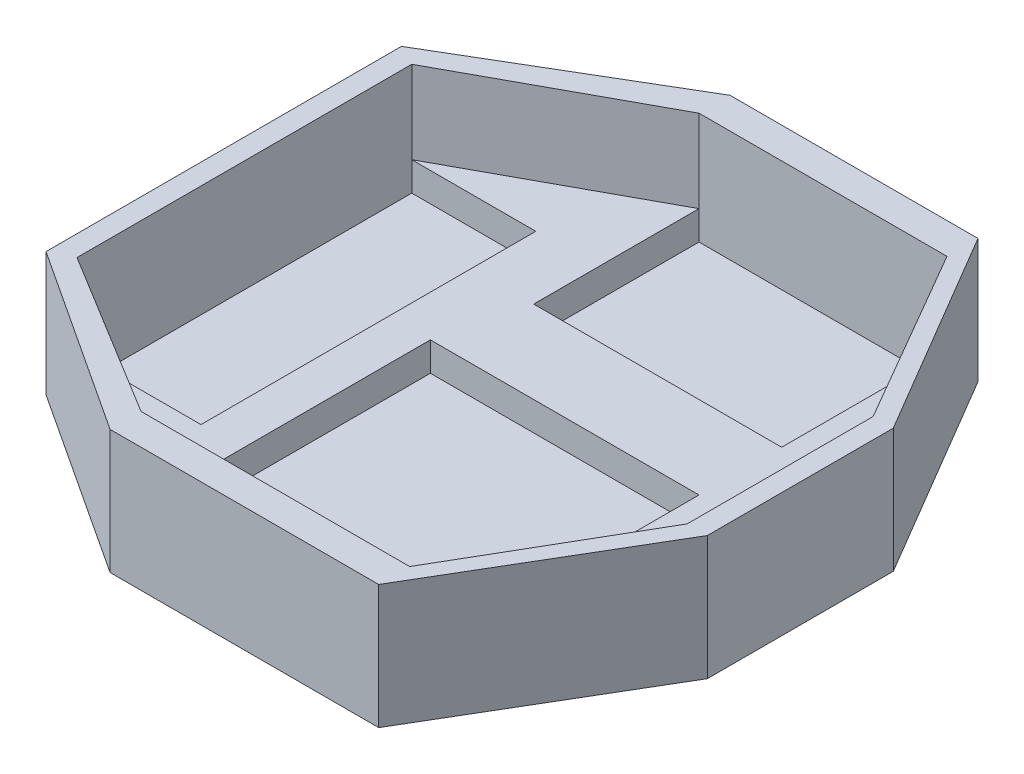
from build123d import *

# Parameters (mm, degrees)
SKETCH1_R           = 85
BOSS_EXTRUDE2_DEPTH = 10
SKETCH3_W           = 30
SKETCH3_H           = 81
SKETCH3_W_2         = 60
SKETCH3_H_2         = 40
SKETCH3_W_3         = 65
SKETCH3_H_3         = 70
CUT_EXTRUDE2_DEPTH  = 7
SKETCH5_W           = 194.063046405
SKETCH5_H           = 184.49419377
CUT_EXTRUDE4_DEPTH  = 10
BOSS_EXTRUDE3_DEPTH = 20


with BuildPart() as part:
    # Sketch1 → Boss-Extrude2 (new body)
    with BuildSketch(Plane(origin=(0, 0, 0), x_dir=(1, 0, 0), z_dir=(0, 1, 0))):
        Circle(SKETCH1_R)
    extrude(amount=BOSS_EXTRUDE2_DEPTH)

    # Sketch3 → Cut-Extrude2 (cut)
    with BuildSketch(Plane(origin=(0, 10, 0), x_dir=(1, 0, 0), z_dir=(0, 1, 0))):
        with Locations((-50, 0)):
            Rectangle(SKETCH3_W, SKETCH3_H)
        with Locations((10, 45)):
            Rectangle(SKETCH3_W_2, SKETCH3_H_2)
        with Locations((7.5, -30)):
            Rectangle(SKETCH3_W_3, SKETCH3_H_3)
    extrude(amount=-CUT_EXTRUDE2_DEPTH, mode=Mode.SUBTRACT)

    # Sketch5 → Cut-Extrude4 (cut)
    with BuildSketch(Plane(origin=(0, 10, 0), x_dir=(1, 0, 0), z_dir=(0, 1, 0))):
        with Locations((-1.510871468, -0.083937304)):
            Rectangle(SKETCH5_W, SKETCH5_H)
        Polygon((-70, 43), (-20, 72.5), (40, 72.5), (69.5, 22.5), (69.5, -22.5), (40, -72.5), (-25, -72.5), (-70, -43), align=None, mode=Mode.SUBTRACT)
    extrude(amount=-CUT_EXTRUDE4_DEPTH, mode=Mode.SUBTRACT)

    # Sketch6 → Boss-Extrude3 (add)
    with BuildSketch(Plane(origin=(0, 10, 0), x_dir=(1, 0, 0), z_dir=(0, 1, 0))):
        Polygon((-70, 43), (-20, 72.5), (38.257502672, 72.5), (40, 72.5), (69.5, 22.5), (69.5, -22.5), (40, -72.5), (-25, -72.5), (-70, -43), align=None)
        Polygon((-65, 40.5), (-65, -40.5), (-25, -65), (40, -65), (64.618640633, -22.5), (64.618640633, 22.5), (40, 65), (-20, 65), align=None, mode=Mode.SUBTRACT)
    extrude(amount=BOSS_EXTRUDE3_DEPTH)


solid = part.part
